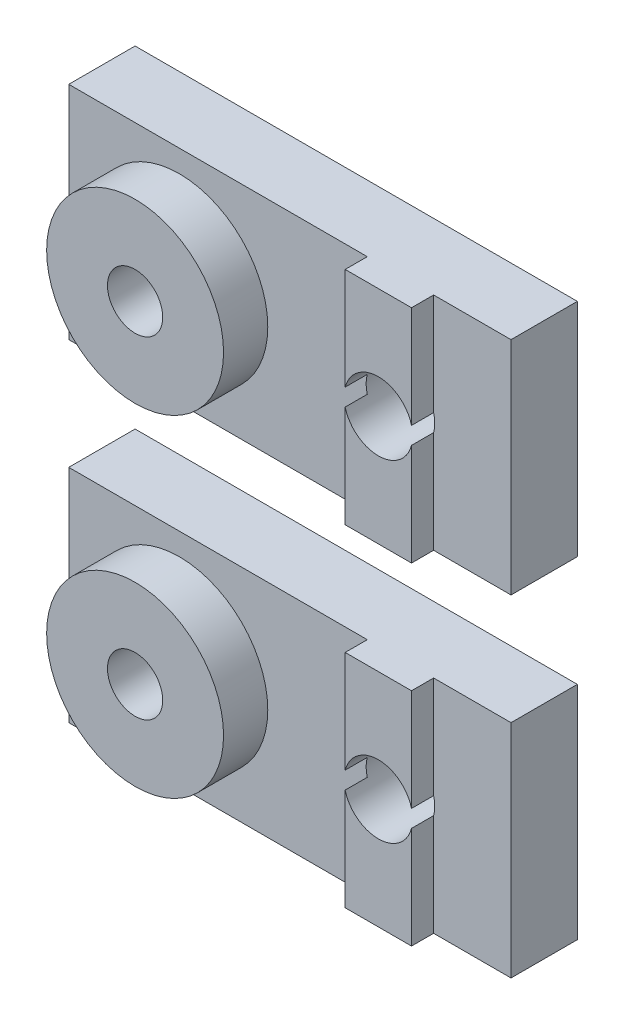
from build123d import *

# Parameters (mm, degrees)
SKETCH1_W           = 20
SKETCH1_H           = 10
BOSS_EXTRUDE1_DEPTH = 3
SKETCH2_R           = 4
SKETCH2_R_2         = 1.25
BOSS_EXTRUDE2_DEPTH = 2
SKETCH3_W           = 3
SKETCH3_H           = 10
BOSS_EXTRUDE3_DEPTH = 1
SKETCH4_R           = 1.25
SKETCH4_R_2         = 1.55
CUT_EXTRUDE1_DEPTH  = 6
LPATTERN1_COUNT     = 2
LPATTERN1_PITCH     = 15


with BuildPart() as part:
    # Sketch1 → Boss-Extrude1 (new body)
    with BuildSketch(Plane.XY):
        with Locations((0, 5)):
            Rectangle(SKETCH1_W, SKETCH1_H)
    extrude(amount=BOSS_EXTRUDE1_DEPTH)

    # Sketch2 → Boss-Extrude2 (add)
    with BuildSketch(Plane.XY.offset(3)):
        with Locations((-5, 5)):
            Circle(SKETCH2_R)
        with Locations((-5, 5)):
            Circle(SKETCH2_R_2, mode=Mode.SUBTRACT)
    extrude(amount=BOSS_EXTRUDE2_DEPTH)

    # Sketch3 → Boss-Extrude3 (add)
    with BuildSketch(Plane.XY.offset(3)):
        with Locations((5, 5)):
            Rectangle(SKETCH3_W, SKETCH3_H)
    extrude(amount=BOSS_EXTRUDE3_DEPTH)

    # Sketch4 → Cut-Extrude1 (cut, through all)
    with BuildSketch(Plane.XY):
        with Locations((-5, 5)):
            Circle(SKETCH4_R)
        with Locations((5, 5)):
            Circle(SKETCH4_R_2)
    extrude(amount=CUT_EXTRUDE1_DEPTH, mode=Mode.SUBTRACT)


with BuildPart() as lpattern1_1:
    # LPattern1: pattern copy
    add(part.part.moved(Location(Vector(0, 1, 0) * (1 * LPATTERN1_PITCH))))


solid = Compound([part.part, lpattern1_1.part])
